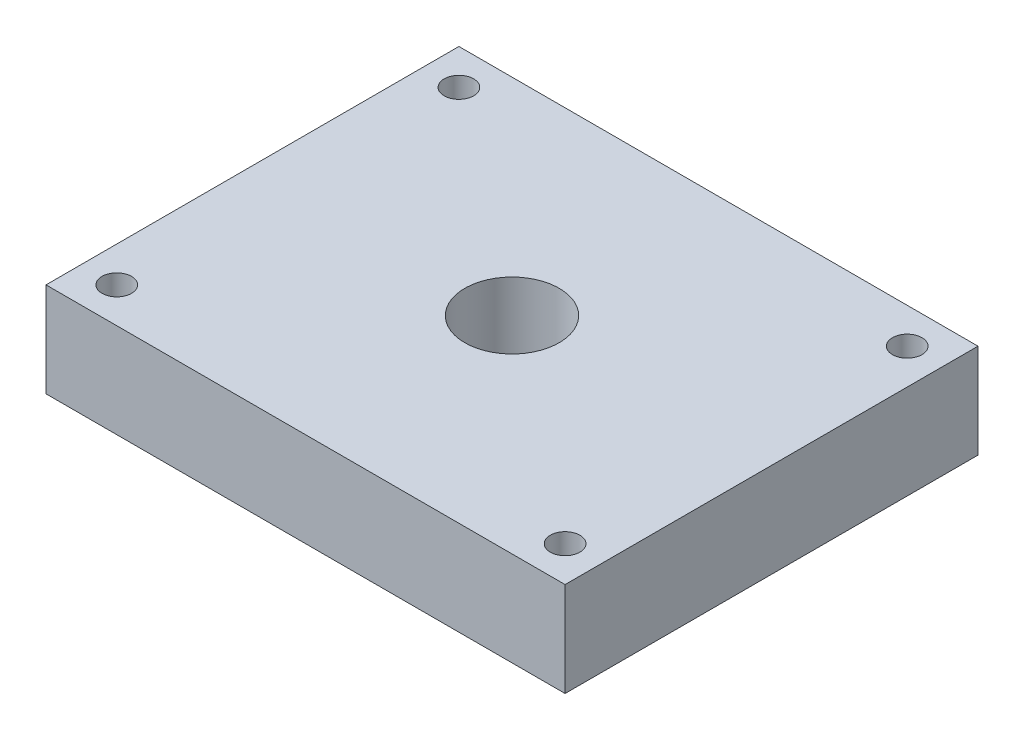
from build123d import *

# Parameters (mm, degrees)
SKETCH16_W          = 44
SKETCH16_H          = 35
SKETCH16_R          = 1.25
BOSS_EXTRUDE1_DEPTH = 8
SKETCH1_R           = 4
CUT_EXTRUDE3_DEPTH  = 9


with BuildPart() as part:
    # Sketch16 → Boss-Extrude1 (new body)
    with BuildSketch(Plane(origin=(0, 0, 0), x_dir=(-1, 0, 0), z_dir=(0, 1, 0))):
        Rectangle(SKETCH16_W, SKETCH16_H)
        with Locations((-19, 14.5)):
            Circle(SKETCH16_R, mode=Mode.SUBTRACT)
        with Locations((19, 14.5)):
            Circle(SKETCH16_R, mode=Mode.SUBTRACT)
        with Locations((19, -14.5)):
            Circle(SKETCH16_R, mode=Mode.SUBTRACT)
        with Locations((-19, -14.5)):
            Circle(SKETCH16_R, mode=Mode.SUBTRACT)
    extrude(amount=BOSS_EXTRUDE1_DEPTH)

    # Sketch1 → Cut-Extrude3 (cut, through all)
    with BuildSketch(Plane(origin=(0, 0, 0), x_dir=(1, 0, 0), z_dir=(0, 1, 0))):
        Circle(SKETCH1_R)
    extrude(amount=CUT_EXTRUDE3_DEPTH, mode=Mode.SUBTRACT)


solid = part.part
